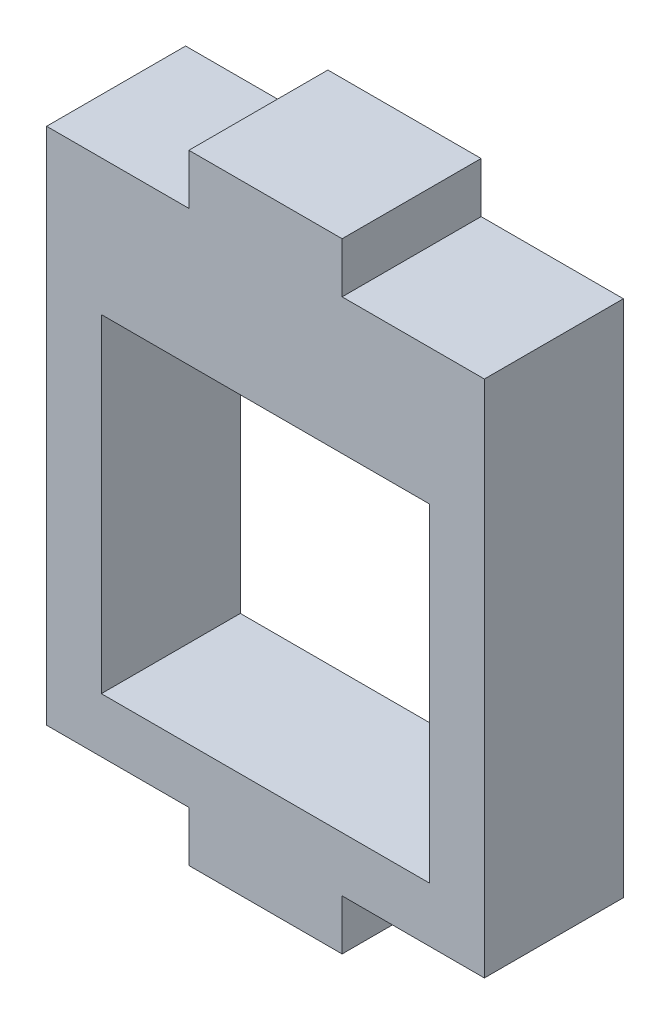
from build123d import *

# Parameters (mm, degrees)
BOSS_EXTRUDE1_DEPTH = 6.35
SKETCH2_W           = 20
SKETCH2_H           = 2.5
BOSS_EXTRUDE2_DEPTH = 6.35
SKETCH4_W           = 7
SKETCH4_H           = 2.3
BOSS_EXTRUDE3_DEPTH = 6.35


with BuildPart() as part:
    # Sketch1 → Boss-Extrude1 (new body)
    with BuildSketch(Plane.XY):
        Polygon((-15.235299292, 17.883619427), (-15.235299292, 2.883619427), (-0.235299292, 2.883619427), (-0.235299292, 17.883619427), (2.264700708, 17.883619427), (2.264700708, 0.383619427), (-17.735299292, 0.383619427), (-17.735299292, 17.883619427), align=None)
    extrude(amount=BOSS_EXTRUDE1_DEPTH)

    # Sketch2 → Boss-Extrude2 (add, through all)
    with BuildSketch(Plane.XY):
        with Locations((-7.735299292, 19.133619427)):
            Rectangle(SKETCH2_W, SKETCH2_H)
    extrude(amount=BOSS_EXTRUDE2_DEPTH)

    # Sketch4 → Boss-Extrude3 (add)
    with BuildSketch(Plane.XY.offset(6.35)):
        Polygon((-17.735299292, 20.383619427), (2.264700708, 20.383619427), (2.264700708, 24.083619427), (-4.235299292, 24.083619427), (-4.235299292, 26.383619427), (-11.235299292, 26.383619427), (-11.235299292, 24.083619427), (-17.735299292, 24.083619427), align=None)
        with Locations((-7.735299292, -0.766380573)):
            Rectangle(SKETCH4_W, SKETCH4_H)
    extrude(amount=-BOSS_EXTRUDE3_DEPTH)


solid = part.part
